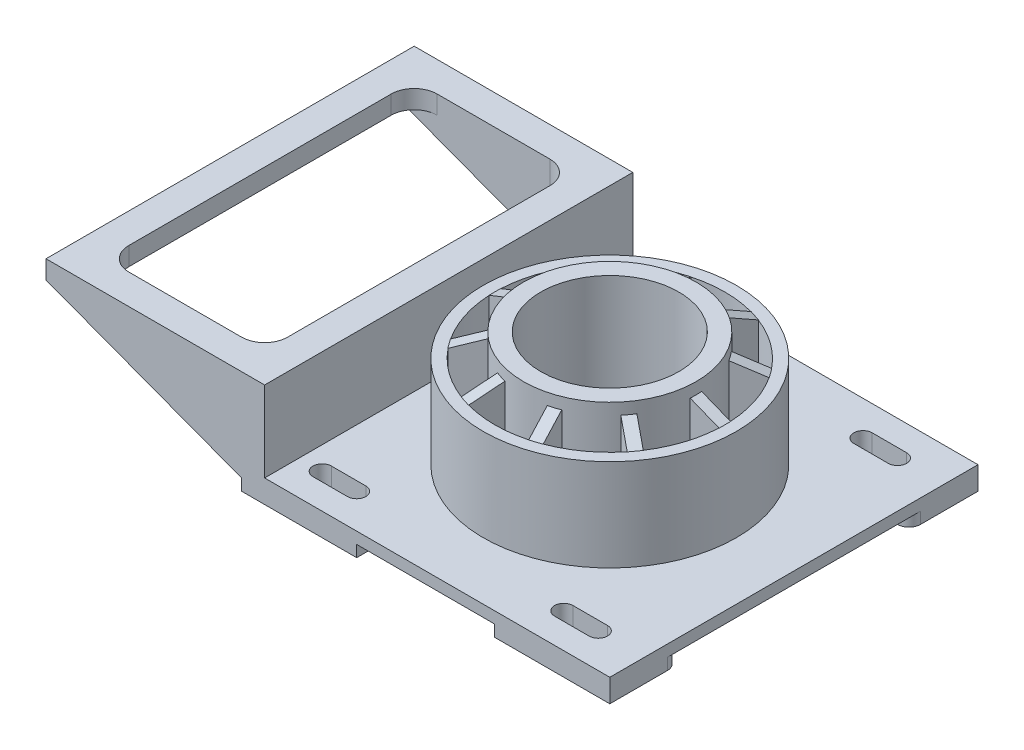
from build123d import *

# Parameters (mm, degrees)
BOSS_EXTRUDE1_DEPTH = 80
CUT_EXTRUDE1_REACH  = 42
CUT_EXTRUDE2_REACH  = 247
SKETCH3_W           = 134
SKETCH3_H           = 8.658823529
SKETCH4_R           = 25
SKETCH4_R_2         = 20
BOSS_EXTRUDE2_DEPTH = 30
SKETCH5_W           = 50
SKETCH5_H           = 30
BOSS_EXTRUDE4_DEPTH = 5
FILLET1_R           = 5
CUT_EXTRUDE5_REACH  = 47
SKETCH11_R          = 37.5
SKETCH11_R_2        = 30
BOSS_EXTRUDE6_DEPTH = 50
SKETCH12_R          = 55
SKETCH12_R_2        = 50
BOSS_EXTRUDE7_DEPTH = 40
RIB1_REACH          = 82
SKETCH13_WALL_W     = 175.462912018
SKETCH13_WALL_H     = 5
CIRPATTERN1_COUNT   = 10


with BuildPart() as part:
    # Sketch1 → Boss-Extrude1 (new body, symmetric)
    with BuildSketch(Plane.XY):
        Polygon((150, -40), (150, -35), (0, -35), (0, 0), (-95, 0), (-95, -8), (-10, -40), align=None)
    extrude(amount=BOSS_EXTRUDE1_DEPTH, both=True)

    # Cut-Extrude1: up to this plane
    cut_extrude1_end = Plane(origin=(-95, -8, 80), z_dir=(0.352329759, 0.935875922, 0))
    # Sketch2 → Cut-Extrude1 (cut, up to the surface)
    with BuildSketch(Plane(origin=(0, 0, 0), x_dir=(-1, 0, 0), z_dir=(0, 1, 0)), mode=Mode.PRIVATE) as cut_extrude1_sk1:
        with BuildLine():
            Line((23, 67), (72, 67))
            ThreePointArc((72, 67), (79.071067812, 64.071067812), (82, 57))
            Line((82, 57), (82, -57))
            ThreePointArc((82, -57), (79.071067812, -64.071067812), (72, -67))
            Line((72, -67), (23, -67))
            ThreePointArc((23, -67), (15.928932188, -64.071067812), (13, -57))
            Line((13, -57), (13, 57))
            ThreePointArc((13, 57), (15.928932188, 64.071067812), (23, 67))
        make_face()
    cut_extrude1_tool1 = split(extrude(cut_extrude1_sk1.sketch, amount=-CUT_EXTRUDE1_REACH, mode=Mode.PRIVATE), bisect_by=cut_extrude1_end, keep=Keep.BOTH, mode=Mode.PRIVATE)
    add(cut_extrude1_tool1.solids().sort_by_distance((-47.5, 0, 0))[0], mode=Mode.SUBTRACT)

    # Sketch3 → Cut-Extrude2 (cut, up to next)
    with BuildSketch(Plane.ZY.offset(95), mode=Mode.PRIVATE) as cut_extrude2_sk1:
        with Locations((0, -12.329411764)):
            Rectangle(SKETCH3_W, SKETCH3_H)
    cut_extrude2_tool1 = extrude(cut_extrude2_sk1.sketch, amount=-CUT_EXTRUDE2_REACH, mode=Mode.PRIVATE) & part.part
    add(cut_extrude2_tool1.solids().sort_by_distance((-95, -12.329412, 0))[0], mode=Mode.SUBTRACT)

    # Sketch4 → Boss-Extrude2 (add)
    with BuildSketch(Plane(origin=(0, -40, 0), x_dir=(-1, 0, 0), z_dir=(0, -1, 0))):
        with Locations((-70, 0)):
            Circle(SKETCH4_R)
        with Locations(Location((-70, 0, 0), (0, 0, 180))):  # turned: the seam where the file's is
            Circle(SKETCH4_R_2, mode=Mode.SUBTRACT)
    extrude(amount=BOSS_EXTRUDE2_DEPTH)

    # Sketch5 → Boss-Extrude4 (add)
    with BuildSketch(Plane(origin=(0, -40, 0), x_dir=(-1, 0, 0), z_dir=(0, -1, 0))):
        with Locations((-125, 65)):
            Rectangle(SKETCH5_W, SKETCH5_H)
        with Locations((-15, 65)):
            Rectangle(SKETCH5_W, SKETCH5_H)
        with Locations((-15, -65)):
            Rectangle(SKETCH5_W, SKETCH5_H)
        with Locations((-125, -65)):
            Rectangle(SKETCH5_W, SKETCH5_H)
    extrude(amount=BOSS_EXTRUDE4_DEPTH)

    # Fillet1
    fillet1_edges = [part.edges().sort_by_distance(p)[0] for p in [
        (150, -42.5, 50),
        (100, -42.5, 50),
        (150, -42.5, -50),
        (100, -42.5, -50),
        (40, -42.5, -50),
        (40, -42.5, 50),
    ]]
    fillet(fillet1_edges, radius=FILLET1_R)

    # Sketch10 → Cut-Extrude5 (cut, up to next)
    with BuildSketch(Plane(origin=(0, -45, 0), x_dir=(-1, 0, 0), z_dir=(0, -1, 0)), mode=Mode.PRIVATE) as cut_extrude5_sk1:
        with BuildLine():
            Line((-130, 69), (-115, 69))
            ThreePointArc((-115, 69), (-111, 65), (-115, 61))
            Line((-115, 61), (-130, 61))
            ThreePointArc((-130, 61), (-134, 65), (-130, 69))
        make_face()
    cut_extrude5_tool1 = extrude(cut_extrude5_sk1.sketch, amount=-CUT_EXTRUDE5_REACH, mode=Mode.PRIVATE) & part.part
    add(cut_extrude5_tool1.solids().sort_by_distance((122.5, -45, -65))[0], mode=Mode.SUBTRACT)
    # Sketch10 → Cut-Extrude5 (cut, up to next)
    with BuildSketch(Plane(origin=(0, -45, 0), x_dir=(-1, 0, 0), z_dir=(0, -1, 0)), mode=Mode.PRIVATE) as cut_extrude5_sk2:
        with BuildLine():
            Line((-10, 69), (-25, 69))
            ThreePointArc((-25, 69), (-29, 65), (-25, 61))
            Line((-25, 61), (-10, 61))
            ThreePointArc((-10, 61), (-6, 65), (-10, 69))
        make_face()
    cut_extrude5_tool2 = extrude(cut_extrude5_sk2.sketch, amount=-CUT_EXTRUDE5_REACH, mode=Mode.PRIVATE) & part.part
    add(cut_extrude5_tool2.solids().sort_by_distance((17.5, -45, -65))[0], mode=Mode.SUBTRACT)
    # Sketch10 → Cut-Extrude5 (cut, up to next)
    with BuildSketch(Plane(origin=(0, -45, 0), x_dir=(-1, 0, 0), z_dir=(0, -1, 0)), mode=Mode.PRIVATE) as cut_extrude5_sk3:
        with BuildLine():
            Line((-130, -69), (-115, -69))
            ThreePointArc((-115, -69), (-111, -65), (-115, -61))
            Line((-115, -61), (-130, -61))
            ThreePointArc((-130, -61), (-134, -65), (-130, -69))
        make_face()
    cut_extrude5_tool3 = extrude(cut_extrude5_sk3.sketch, amount=-CUT_EXTRUDE5_REACH, mode=Mode.PRIVATE) & part.part
    add(cut_extrude5_tool3.solids().sort_by_distance((122.5, -45, 65))[0], mode=Mode.SUBTRACT)
    # Sketch10 → Cut-Extrude5 (cut, up to next)
    with BuildSketch(Plane(origin=(0, -45, 0), x_dir=(-1, 0, 0), z_dir=(0, -1, 0)), mode=Mode.PRIVATE) as cut_extrude5_sk4:
        with BuildLine():
            Line((-10, -69), (-25, -69))
            ThreePointArc((-25, -69), (-29, -65), (-25, -61))
            Line((-25, -61), (-10, -61))
            ThreePointArc((-10, -61), (-6, -65), (-10, -69))
        make_face()
    cut_extrude5_tool4 = extrude(cut_extrude5_sk4.sketch, amount=-CUT_EXTRUDE5_REACH, mode=Mode.PRIVATE) & part.part
    add(cut_extrude5_tool4.solids().sort_by_distance((17.5, -45, 65))[0], mode=Mode.SUBTRACT)

    # Sketch11 → Boss-Extrude6 (add)
    with BuildSketch(Plane(origin=(0, -35, 0), x_dir=(-1, 0, 0), z_dir=(0, 1, 0))):
        with Locations(Location((-70, 0, 0), (0, 0, 180))):  # turned: the seam where the file's is
            Circle(SKETCH11_R)
        with Locations(Location((-70, 0, 0), (0, 0, 90))):  # turned: the seam where the file's is
            Circle(SKETCH11_R_2, mode=Mode.SUBTRACT)
    extrude(amount=BOSS_EXTRUDE6_DEPTH)

    # Sketch12 → Boss-Extrude7 (add)
    with BuildSketch(Plane(origin=(0, -35, 0), x_dir=(-1, 0, 0), z_dir=(0, 1, 0))):
        with Locations(Location((-70, 0, 0), (0, 0, 180))):  # turned: the seam where the file's is
            Circle(SKETCH12_R)
        with Locations(Location((-70, 0, 0), (0, 0, 90))):  # turned: the seam where the file's is
            Circle(SKETCH12_R_2, mode=Mode.SUBTRACT)
    extrude(amount=BOSS_EXTRUDE7_DEPTH)

    # Sketch13 wall → Rib1 (add, up to next)
    with BuildSketch(Plane(origin=(26.25, 7.5, 0), x_dir=(0.928476691, 0.371390676, 0), z_dir=(-0.371390676, 0.928476691, 0)), mode=Mode.PRIVATE) as rib1_sk1:
        Rectangle(SKETCH13_WALL_W, SKETCH13_WALL_H)
    rib1_tool1 = extrude(rib1_sk1.sketch, amount=-RIB1_REACH, mode=Mode.PRIVATE) - part.part
    rib1 = rib1_tool1.solids().sort_by_distance((26.25, 7.5, 0))[0]
    add(rib1)

    # CirPattern1: Rib1 ×10 about axis
    cirpattern1_axis = Axis((70, 0, 0), (0, 1, 0))
    for i in range(1, CIRPATTERN1_COUNT):
        add(rib1.rotate(cirpattern1_axis, i * 360 / CIRPATTERN1_COUNT))


solid = part.part
